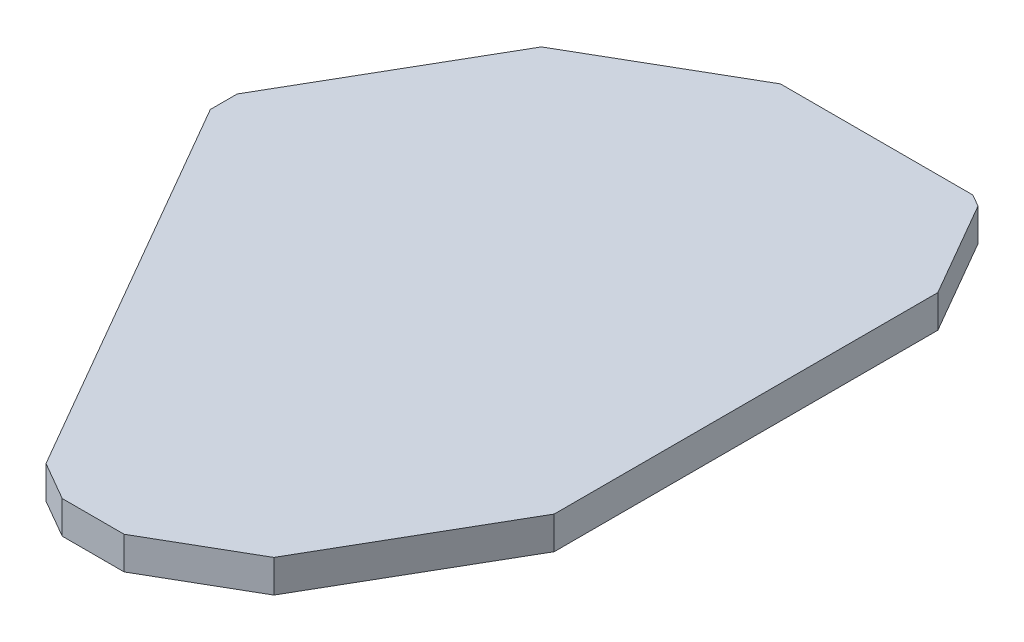
from build123d import *

# Parameters (mm, degrees)
AUFSATZ_LINEAR_AUSTRAGEN1_DEPTH = 1


with BuildPart() as part:
    # Skizze1 → Aufsatz-Linear austragen1 (new body)
    with BuildSketch(Plane(origin=(0, 0, 0), x_dir=(1, 0, 0), z_dir=(0, 1, 0))):
        Polygon((4.947441117, 11), (-0.947441117, 11), (-5.588457268, 8.320508076), (-9, 2.411542732), (-9, 1.588457268), (-2.124355653, -10.320508076), (-0.947441117, -11), (0.948564057, -11), (3.855844991, -9.32148057), (7, -3.875644347), (7, 7.875644347), (5.320508076, 10.784609691), align=None)
    extrude(amount=AUFSATZ_LINEAR_AUSTRAGEN1_DEPTH)


solid = part.part
